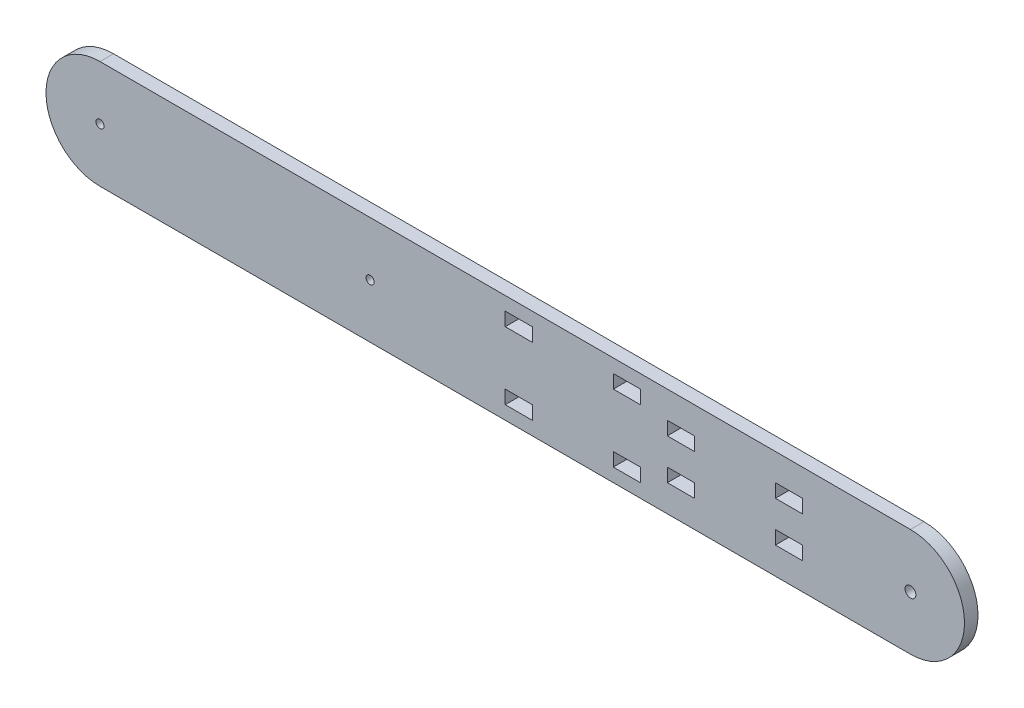
from build123d import *

# Parameters (mm, degrees)
SKETCH1_R           = 1.5
SKETCH1_R_2         = 2
SKETCH1_W           = 10
SKETCH1_H           = 5
BOSS_EXTRUDE2_DEPTH = 5


with BuildPart() as part:
    # Sketch1 → Boss-Extrude2 (new body)
    with BuildSketch(Plane.XY):
        with BuildLine():
            Line((-126.904376013, 20), (173.095623987, 20))
            ThreePointArc((173.095623987, 20), (193.095623987, 0), (173.095623987, -20))
            Line((173.095623987, -20), (-126.904376013, -20))
            ThreePointArc((-126.904376013, -20), (-146.904376013, 0), (-126.904376013, 20))
        make_face()
        with Locations((-126.904376013, 0)):
            Circle(SKETCH1_R, mode=Mode.SUBTRACT)
        with Locations((173.095623987, 0)):
            Circle(SKETCH1_R_2, mode=Mode.SUBTRACT)
        with Locations((-26.904376013, 0)):
            Circle(SKETCH1_R, mode=Mode.SUBTRACT)
        with Locations((28.095623987, 12.5)):
            Rectangle(SKETCH1_W, SKETCH1_H, mode=Mode.SUBTRACT)
        with Locations((68.095623987, 12.5)):
            Rectangle(SKETCH1_W, SKETCH1_H, mode=Mode.SUBTRACT)
        with Locations((88.095623987, 7.5)):
            Rectangle(SKETCH1_W, SKETCH1_H, mode=Mode.SUBTRACT)
        with Locations((128.095623987, 7.5)):
            Rectangle(SKETCH1_W, SKETCH1_H, mode=Mode.SUBTRACT)
        with Locations((28.095623987, -12.5)):
            Rectangle(SKETCH1_W, SKETCH1_H, mode=Mode.SUBTRACT)
        with Locations((68.095623987, -12.5)):
            Rectangle(SKETCH1_W, SKETCH1_H, mode=Mode.SUBTRACT)
        with Locations((88.095623987, -7.5)):
            Rectangle(SKETCH1_W, SKETCH1_H, mode=Mode.SUBTRACT)
        with Locations((128.095623987, -7.5)):
            Rectangle(SKETCH1_W, SKETCH1_H, mode=Mode.SUBTRACT)
    extrude(amount=BOSS_EXTRUDE2_DEPTH)


solid = part.part
